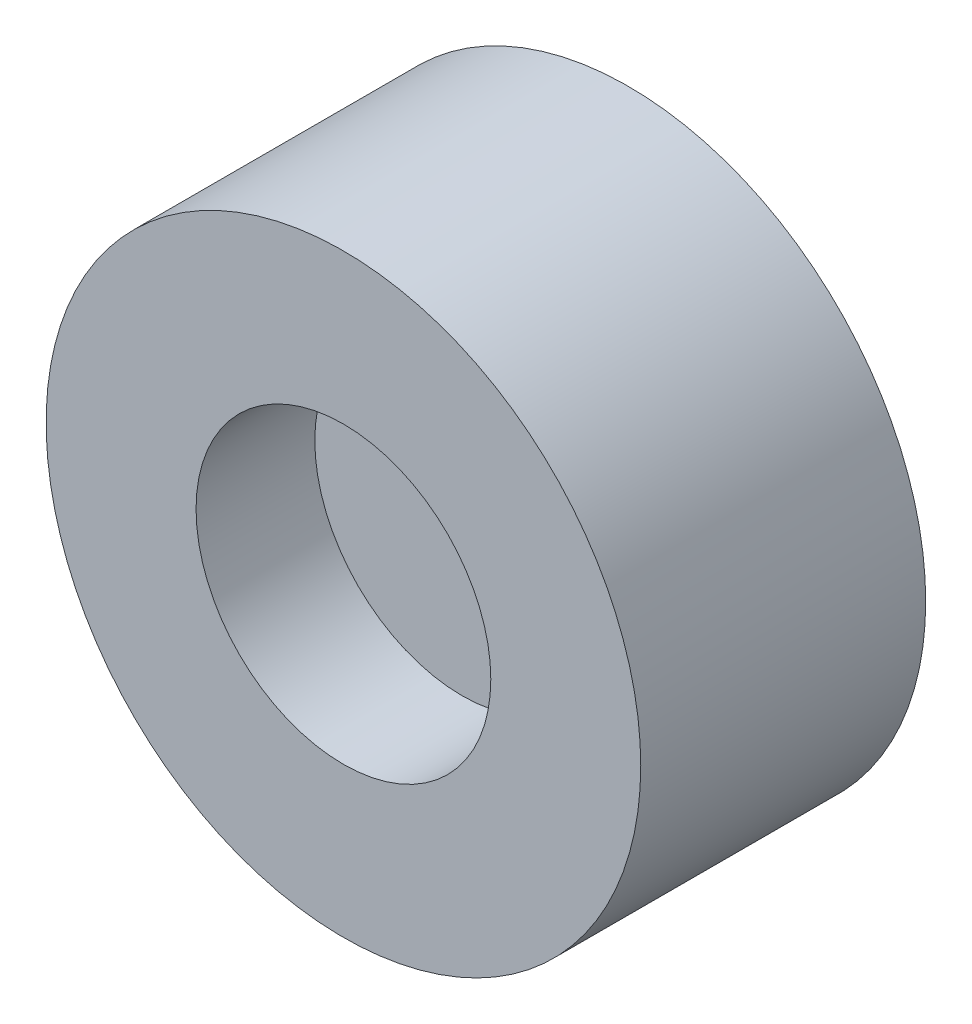
from build123d import *

# Parameters (mm, degrees)
SKETCH1_R           = 31.031300013
SKETCH1_R_2         = 3.067047094
EXTRUDE3_DEPTH      = 5
EXTRUDE3_DEPTH_BACK = 5
SKETCH1_6_R         = 62.603843631
SKETCH1_6_R_2       = 31.031300013
EXTRUDE4_DEPTH      = 30
EXTRUDE4_DEPTH_BACK = 30


with BuildPart() as part:
    # Sketch1 → Extrude3 (new body, two sides)
    with BuildSketch(Plane.XY) as extrude3_sk:
        Circle(SKETCH1_R)
        Circle(SKETCH1_R_2, mode=Mode.SUBTRACT)
    extrude(amount=EXTRUDE3_DEPTH)
    extrude(extrude3_sk.sketch, amount=-EXTRUDE3_DEPTH_BACK)

    # Sketch1_6 → Extrude4 (add, two sides)
    with BuildSketch(Plane.XY) as extrude4_sk:
        Circle(SKETCH1_6_R)
        Circle(SKETCH1_6_R_2, mode=Mode.SUBTRACT)
    extrude(amount=EXTRUDE4_DEPTH)
    extrude(extrude4_sk.sketch, amount=-EXTRUDE4_DEPTH_BACK)


solid = part.part
